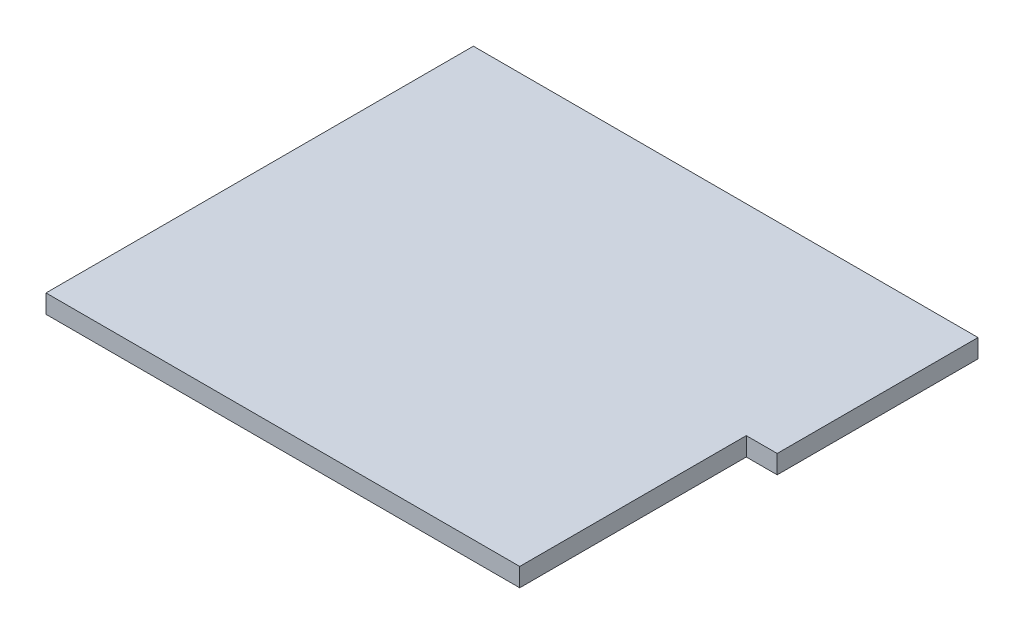
from build123d import *

# Parameters (mm, degrees)
DODANIE_WYCI_GNI_CIE1_DEPTH = 15
SKORUPA1_T                  = 3


with BuildPart() as part:
    # Szkic1 → Dodanie-wyciągnięcie1 (new body)
    with BuildSketch(Plane(origin=(0, 0, 0), x_dir=(1, 0, 0), z_dir=(0, 1, 0))):
        Polygon((0, 0), (454, 0), (454, 220), (484, 220), (484, 409), (0, 409), align=None)
    extrude(amount=-DODANIE_WYCI_GNI_CIE1_DEPTH)

    # Skorupa1
    skorupa1_openings = [part.faces().sort_by_distance(p)[0] for p in [
        (234.170613934, -15, -207.75936997),
    ]]
    offset(amount=SKORUPA1_T, openings=skorupa1_openings, kind=Kind.INTERSECTION)


solid = part.part
